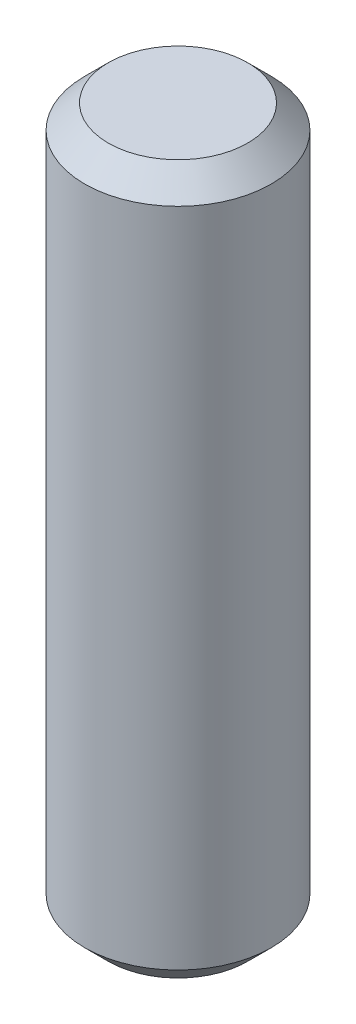
from build123d import *

# Parameters (mm, degrees)
SKETCH1_R           = 3.95
BOSS_EXTRUDE1_DEPTH = 15
CHAMFER1_SIZE       = 1


with BuildPart() as part:
    # Sketch1 → Boss-Extrude1 (new body, symmetric)
    with BuildSketch(Plane(origin=(0, 0, 0), x_dir=(1, 0, 0), z_dir=(0, 1, 0))):
        Circle(SKETCH1_R)
    extrude(amount=BOSS_EXTRUDE1_DEPTH, both=True)

    # Chamfer1
    chamfer1_edges = [part.edges().sort_by_distance(p)[0] for p in [
        (-3.95, -15, 0),
        (-3.95, 15, 0),
    ]]
    chamfer(chamfer1_edges, length=CHAMFER1_SIZE)


solid = part.part
